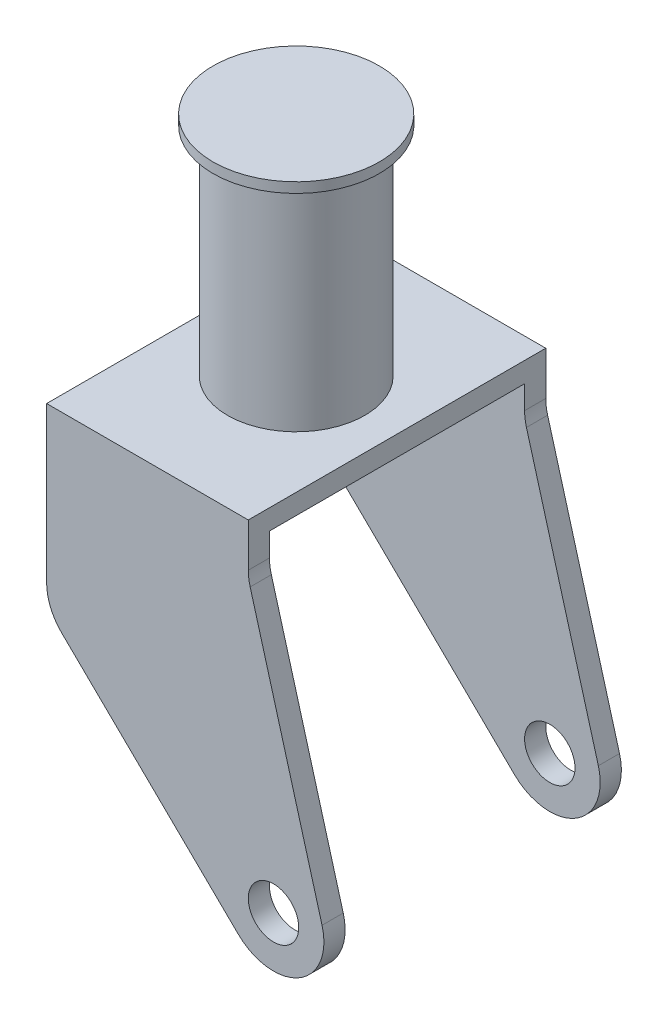
from build123d import *

# Parameters (mm, degrees)
BOSS_EXTRUDE1_DEPTH      = 37.465
BOSS_EXTRUDE1_DEPTH_BACK = 37.465
SKETCH3_W                = 64.262
SKETCH3_H                = 110.648250087
CUT_EXTRUDE1_DEPTH       = 55.118
CUT_EXTRUDE1_DEPTH_BACK  = 109.601
SKETCH4_R                = 6.35
CUT_EXTRUDE2_DEPTH       = 109.601


with BuildPart() as part:
    # Sketch1 → Revolve1 (revolve)
    with BuildSketch(Plane.XY):
        Polygon((0, 57.15), (20.955, 57.15), (20.955, 54.61), (17.272, 54.61), (17.272, 0), (0, 0), align=None)
    revolve(axis=Axis((0, 38.1873125, 0), (0, -1, 0)))

    # Sketch2 → Boss-Extrude1 (add, two sides)
    with BuildSketch(Plane.XY) as boss_extrude1_sk:
        with BuildLine():
            Line((-25.4, 0), (25.4, 0))
            Line((25.4, 0), (25.4, -10.957312238))
            ThreePointArc((25.4, -10.957312238), (25.517902954, -12.683821415), (25.869422667, -14.378273814))
            Line((25.869422667, -14.378273814), (43.980577333, -79.129038424))
            ThreePointArc((43.980577333, -79.129038424), (38.222573525, -93.476838151), (22.872930676, -91.632270653))
            Line((22.872930676, -91.632270653), (-21.577069324, -48.186556851))
            ThreePointArc((-21.577069324, -48.186556851), (-24.405314614, -44.031314693), (-25.4, -39.104286198))
            Line((-25.4, -39.104286198), (-25.4, 0))
        make_face()
    extrude(amount=BOSS_EXTRUDE1_DEPTH)
    extrude(boss_extrude1_sk.sketch, amount=-BOSS_EXTRUDE1_DEPTH_BACK)

    # Sketch3 → Cut-Extrude1 (cut, two sides)
    with BuildSketch(Plane.ZY.offset(25.4)) as cut_extrude1_sk:
        with Locations((0, -60.404125044)):
            Rectangle(SKETCH3_W, SKETCH3_H)
    extrude(amount=CUT_EXTRUDE1_DEPTH, mode=Mode.SUBTRACT)
    extrude(cut_extrude1_sk.sketch, amount=-CUT_EXTRUDE1_DEPTH_BACK, mode=Mode.SUBTRACT)

    # Sketch4 → Cut-Extrude2 (cut)
    with BuildSketch(Plane.XY.offset(37.465)):
        with Locations((31.75, -82.55)):
            Circle(SKETCH4_R)
    extrude(amount=-CUT_EXTRUDE2_DEPTH, mode=Mode.SUBTRACT)


solid = part.part
